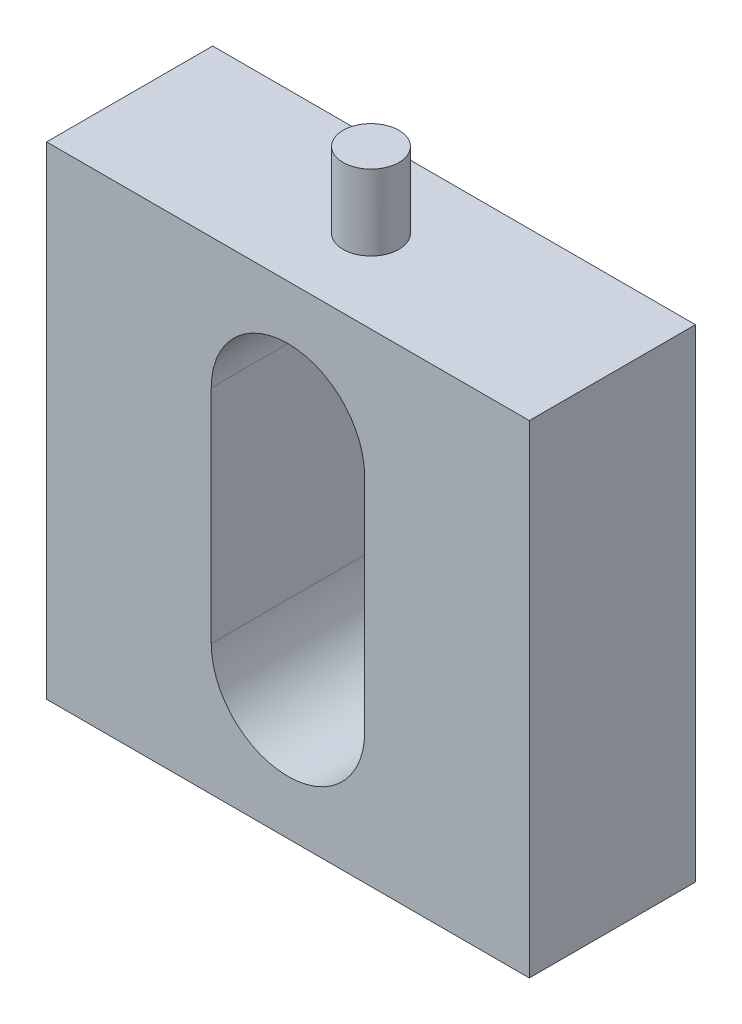
from build123d import *

# Parameters (mm, degrees)
SKETCH1_W           = 13.843
SKETCH1_H           = 13.843
BOSS_EXTRUDE1_DEPTH = 4.7625
SKETCH2_R           = 0.8001
BOSS_EXTRUDE2_DEPTH = 2.159
CUT_EXTRUDE1_DEPTH  = 8.001


with BuildPart() as part:
    # Sketch1 → Boss-Extrude1 (new body)
    with BuildSketch(Plane.XY):
        with Locations((6.9215, -6.9215)):
            Rectangle(SKETCH1_W, SKETCH1_H)
    extrude(amount=BOSS_EXTRUDE1_DEPTH)

    # Sketch2 → Boss-Extrude2 (add)
    with BuildSketch(Plane(origin=(0, 0, 0), x_dir=(1, 0, 0), z_dir=(0, 1, 0))):
        with Locations((6.9215, -2.38125)):
            Circle(SKETCH2_R)
    extrude(amount=BOSS_EXTRUDE2_DEPTH)

    # Sketch3 → Cut-Extrude1 (cut)
    with BuildSketch(Plane(origin=(0, 0, 0), x_dir=(-1, 0, 0), z_dir=(0, 0, -1))):
        with BuildLine():
            Line((-9.1215, -10.0965), (-9.1215, -3.7465))
            ThreePointArc((-9.1215, -3.7465), (-6.9215, -1.5465), (-4.7215, -3.7465))
            Line((-4.7215, -3.7465), (-4.7215, -10.0965))
            ThreePointArc((-4.7215, -10.0965), (-6.9215, -12.2965), (-9.1215, -10.0965))
        make_face()
    extrude(amount=-CUT_EXTRUDE1_DEPTH, mode=Mode.SUBTRACT)


solid = part.part
